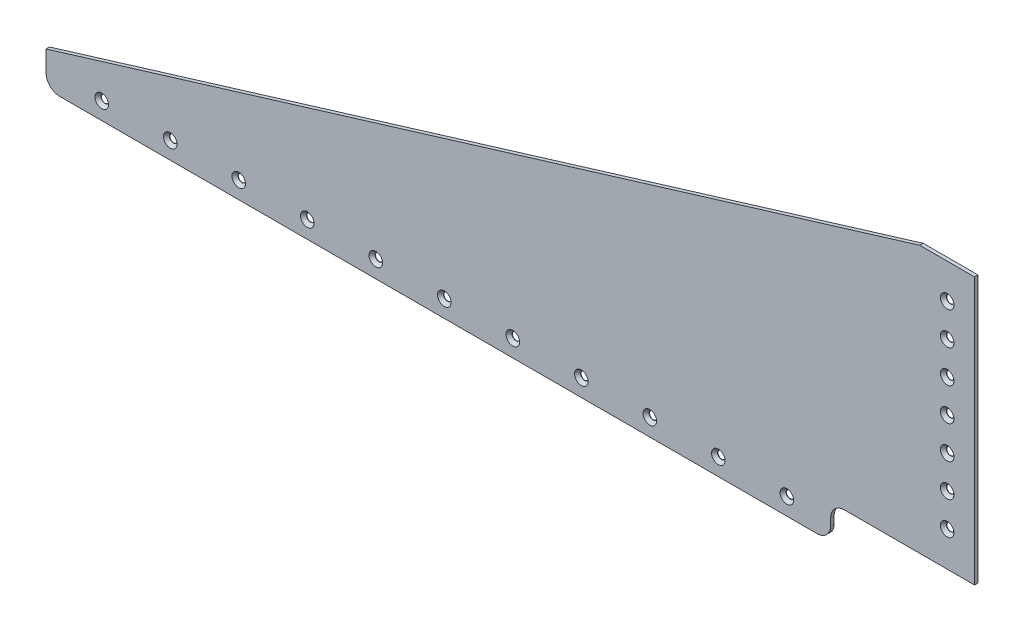
from build123d import *

# Parameters (mm, degrees)
BOSS_EXTRUDE1_DEPTH                           = 1.5875
CSK_FOR_6_FLAT_HEAD_SOCKET_CAP_SCREW1_A_COUNT = 2
CSK_FOR_6_FLAT_HEAD_SOCKET_CAP_SCREW1_A_PITCH = 31.75
CSK_FOR_6_FLAT_HEAD_SOCKET_CAP_SCRE_2_COUNT   = 2
CSK_FOR_6_FLAT_HEAD_SOCKET_CAP_SCRE_2_PITCH   = 63.5
CSK_FOR_6_FLAT_HEAD_SOCKET_CAP_SCRE_3_COUNT   = 2
CSK_FOR_6_FLAT_HEAD_SOCKET_CAP_SCRE_3_PITCH   = 95.25
CSK_FOR_6_FLAT_HEAD_SOCKET_CAP_SCRE_4_COUNT   = 2
CSK_FOR_6_FLAT_HEAD_SOCKET_CAP_SCRE_4_PITCH   = 127
CSK_FOR_6_FLAT_HEAD_SOCKET_CAP_SCRE_5_COUNT   = 2
CSK_FOR_6_FLAT_HEAD_SOCKET_CAP_SCRE_5_PITCH   = 158.75
CSK_FOR_6_FLAT_HEAD_SOCKET_CAP_SCRE_6_COUNT   = 2
CSK_FOR_6_FLAT_HEAD_SOCKET_CAP_SCRE_6_PITCH   = 190.5
CSK_FOR_6_FLAT_HEAD_SOCKET_CAP_SCRE_7_COUNT   = 2
CSK_FOR_6_FLAT_HEAD_SOCKET_CAP_SCRE_7_PITCH   = 222.25
CSK_FOR_6_FLAT_HEAD_SOCKET_CAP_SCRE_8_COUNT   = 2
CSK_FOR_6_FLAT_HEAD_SOCKET_CAP_SCRE_8_PITCH   = 254
CSK_FOR_6_FLAT_HEAD_SOCKET_CAP_SCRE_9_COUNT   = 2
CSK_FOR_6_FLAT_HEAD_SOCKET_CAP_SCRE_9_PITCH   = 285.75
CSK_FOR_6_FLAT_HEAD_SOCKET_CAP_SCRE_10_COUNT  = 2
CSK_FOR_6_FLAT_HEAD_SOCKET_CAP_SCRE_10_PITCH  = 317.5
CSK_FOR_6_FLAT_HEAD_SOCKET_CAP_SCREW2_A_COUNT = 2
CSK_FOR_6_FLAT_HEAD_SOCKET_CAP_SCREW2_A_PITCH = 15.24
CSK_FOR_6_FLAT_HEAD_SOCKET_CAP_SCRE_11_COUNT  = 2
CSK_FOR_6_FLAT_HEAD_SOCKET_CAP_SCRE_11_PITCH  = 30.48
CSK_FOR_6_FLAT_HEAD_SOCKET_CAP_SCRE_12_COUNT  = 2
CSK_FOR_6_FLAT_HEAD_SOCKET_CAP_SCRE_12_PITCH  = 45.72
CSK_FOR_6_FLAT_HEAD_SOCKET_CAP_SCRE_13_COUNT  = 2
CSK_FOR_6_FLAT_HEAD_SOCKET_CAP_SCRE_13_PITCH  = 60.96
CSK_FOR_6_FLAT_HEAD_SOCKET_CAP_SCRE_14_COUNT  = 2
CSK_FOR_6_FLAT_HEAD_SOCKET_CAP_SCRE_14_PITCH  = 76.2
CSK_FOR_6_FLAT_HEAD_SOCKET_CAP_SCRE_15_COUNT  = 2
CSK_FOR_6_FLAT_HEAD_SOCKET_CAP_SCRE_15_PITCH  = 91.44


with BuildPart() as part:
    # Sketch1 → Boss-Extrude1 (new body)
    with BuildSketch(Plane.XY):
        with BuildLine():
            Line((0, 15.875), (404.9268, 139.5476))
            Line((404.9268, 139.5476), (430.3268, 139.5476))
            Line((430.3268, 139.5476), (430.3268, 15.875))
            Line((430.3268, 15.875), (370.0018, 15.875))
            ThreePointArc((370.0018, 15.875), (365.511671939, 14.015128061), (363.6518, 9.525))
            Line((363.6518, 9.525), (363.6518, 6.35))
            ThreePointArc((363.6518, 6.35), (361.791928061, 1.859871939), (357.3018, 0))
            Line((357.3018, 0), (6.35, 0))
            ThreePointArc((6.35, 0), (1.859871939, 1.859871939), (0, 6.35))
            Line((0, 6.35), (0, 15.875))
        make_face()
    extrude(amount=BOSS_EXTRUDE1_DEPTH)

    # Sketch3 → CSK for #6 Flat Head Socket Cap Screw1 (revolve, cut)
    with BuildSketch(Plane(origin=(343.3318, 7.9375, 1.5875), x_dir=(0, -1, 0), z_dir=(1, 0, 0))):
        Polygon((0, 0), (0, 2.6228539), (1.8288, 1.524), (1.8288, 1.504796913), (3.1369, 0), align=None)
    csk_for_6_flat_head_socket_cap_screw1 = revolve(axis=Axis((343.3318, 7.9375, 7.9375), (0, 0, -1)), mode=Mode.SUBTRACT)

    # CSK for #6 Flat Head Socket Cap Screw1 a: CSK for #6 Flat Head Socket Cap Screw1 ×2
    with Locations(*[(-i * CSK_FOR_6_FLAT_HEAD_SOCKET_CAP_SCREW1_A_PITCH, 0, 0) for i in range(1, CSK_FOR_6_FLAT_HEAD_SOCKET_CAP_SCREW1_A_COUNT)]):
        add(csk_for_6_flat_head_socket_cap_screw1, mode=Mode.SUBTRACT)

    # CSK for _6 Flat Head Socket Cap Scre 2: CSK for #6 Flat Head Socket Cap Screw1 ×2
    with Locations(*[(-i * CSK_FOR_6_FLAT_HEAD_SOCKET_CAP_SCRE_2_PITCH, 0, 0) for i in range(1, CSK_FOR_6_FLAT_HEAD_SOCKET_CAP_SCRE_2_COUNT)]):
        add(csk_for_6_flat_head_socket_cap_screw1, mode=Mode.SUBTRACT)

    # CSK for _6 Flat Head Socket Cap Scre 3: CSK for #6 Flat Head Socket Cap Screw1 ×2
    with Locations(*[(-i * CSK_FOR_6_FLAT_HEAD_SOCKET_CAP_SCRE_3_PITCH, 0, 0) for i in range(1, CSK_FOR_6_FLAT_HEAD_SOCKET_CAP_SCRE_3_COUNT)]):
        add(csk_for_6_flat_head_socket_cap_screw1, mode=Mode.SUBTRACT)

    # CSK for _6 Flat Head Socket Cap Scre 4: CSK for #6 Flat Head Socket Cap Screw1 ×2
    with Locations(*[(-i * CSK_FOR_6_FLAT_HEAD_SOCKET_CAP_SCRE_4_PITCH, 0, 0) for i in range(1, CSK_FOR_6_FLAT_HEAD_SOCKET_CAP_SCRE_4_COUNT)]):
        add(csk_for_6_flat_head_socket_cap_screw1, mode=Mode.SUBTRACT)

    # CSK for _6 Flat Head Socket Cap Scre 5: CSK for #6 Flat Head Socket Cap Screw1 ×2
    with Locations(*[(-i * CSK_FOR_6_FLAT_HEAD_SOCKET_CAP_SCRE_5_PITCH, 0, 0) for i in range(1, CSK_FOR_6_FLAT_HEAD_SOCKET_CAP_SCRE_5_COUNT)]):
        add(csk_for_6_flat_head_socket_cap_screw1, mode=Mode.SUBTRACT)

    # CSK for _6 Flat Head Socket Cap Scre 6: CSK for #6 Flat Head Socket Cap Screw1 ×2
    with Locations(*[(-i * CSK_FOR_6_FLAT_HEAD_SOCKET_CAP_SCRE_6_PITCH, 0, 0) for i in range(1, CSK_FOR_6_FLAT_HEAD_SOCKET_CAP_SCRE_6_COUNT)]):
        add(csk_for_6_flat_head_socket_cap_screw1, mode=Mode.SUBTRACT)

    # CSK for _6 Flat Head Socket Cap Scre 7: CSK for #6 Flat Head Socket Cap Screw1 ×2
    with Locations(*[(-i * CSK_FOR_6_FLAT_HEAD_SOCKET_CAP_SCRE_7_PITCH, 0, 0) for i in range(1, CSK_FOR_6_FLAT_HEAD_SOCKET_CAP_SCRE_7_COUNT)]):
        add(csk_for_6_flat_head_socket_cap_screw1, mode=Mode.SUBTRACT)

    # CSK for _6 Flat Head Socket Cap Scre 8: CSK for #6 Flat Head Socket Cap Screw1 ×2
    with Locations(*[(-i * CSK_FOR_6_FLAT_HEAD_SOCKET_CAP_SCRE_8_PITCH, 0, 0) for i in range(1, CSK_FOR_6_FLAT_HEAD_SOCKET_CAP_SCRE_8_COUNT)]):
        add(csk_for_6_flat_head_socket_cap_screw1, mode=Mode.SUBTRACT)

    # CSK for _6 Flat Head Socket Cap Scre 9: CSK for #6 Flat Head Socket Cap Screw1 ×2
    with Locations(*[(-i * CSK_FOR_6_FLAT_HEAD_SOCKET_CAP_SCRE_9_PITCH, 0, 0) for i in range(1, CSK_FOR_6_FLAT_HEAD_SOCKET_CAP_SCRE_9_COUNT)]):
        add(csk_for_6_flat_head_socket_cap_screw1, mode=Mode.SUBTRACT)

    # CSK for _6 Flat Head Socket Cap Scre 10: CSK for #6 Flat Head Socket Cap Screw1 ×2
    with Locations(*[(-i * CSK_FOR_6_FLAT_HEAD_SOCKET_CAP_SCRE_10_PITCH, 0, 0) for i in range(1, CSK_FOR_6_FLAT_HEAD_SOCKET_CAP_SCRE_10_COUNT)]):
        add(csk_for_6_flat_head_socket_cap_screw1, mode=Mode.SUBTRACT)

    # Sketch5 → CSK for #6 Flat Head Socket Cap Screw2 (revolve, cut)
    with BuildSketch(Plane(origin=(417.6268, 123.4313, 1.5875), x_dir=(0, -1, 0), z_dir=(1, 0, 0))):
        Polygon((0, 0), (0, 2.6228539), (1.8288, 1.524), (1.8288, 1.504796913), (3.1369, 0), align=None)
    csk_for_6_flat_head_socket_cap_screw2 = revolve(axis=Axis((417.6268, 123.4313, 7.9375), (0, 0, -1)), mode=Mode.SUBTRACT)

    # CSK for #6 Flat Head Socket Cap Screw2 a: CSK for #6 Flat Head Socket Cap Screw2 ×2
    with Locations(*[(0, -i * CSK_FOR_6_FLAT_HEAD_SOCKET_CAP_SCREW2_A_PITCH, 0) for i in range(1, CSK_FOR_6_FLAT_HEAD_SOCKET_CAP_SCREW2_A_COUNT)]):
        add(csk_for_6_flat_head_socket_cap_screw2, mode=Mode.SUBTRACT)

    # CSK for _6 Flat Head Socket Cap Scre 11: CSK for #6 Flat Head Socket Cap Screw2 ×2
    with Locations(*[(0, -i * CSK_FOR_6_FLAT_HEAD_SOCKET_CAP_SCRE_11_PITCH, 0) for i in range(1, CSK_FOR_6_FLAT_HEAD_SOCKET_CAP_SCRE_11_COUNT)]):
        add(csk_for_6_flat_head_socket_cap_screw2, mode=Mode.SUBTRACT)

    # CSK for _6 Flat Head Socket Cap Scre 12: CSK for #6 Flat Head Socket Cap Screw2 ×2
    with Locations(*[(0, -i * CSK_FOR_6_FLAT_HEAD_SOCKET_CAP_SCRE_12_PITCH, 0) for i in range(1, CSK_FOR_6_FLAT_HEAD_SOCKET_CAP_SCRE_12_COUNT)]):
        add(csk_for_6_flat_head_socket_cap_screw2, mode=Mode.SUBTRACT)

    # CSK for _6 Flat Head Socket Cap Scre 13: CSK for #6 Flat Head Socket Cap Screw2 ×2
    with Locations(*[(0, -i * CSK_FOR_6_FLAT_HEAD_SOCKET_CAP_SCRE_13_PITCH, 0) for i in range(1, CSK_FOR_6_FLAT_HEAD_SOCKET_CAP_SCRE_13_COUNT)]):
        add(csk_for_6_flat_head_socket_cap_screw2, mode=Mode.SUBTRACT)

    # CSK for _6 Flat Head Socket Cap Scre 14: CSK for #6 Flat Head Socket Cap Screw2 ×2
    with Locations(*[(0, -i * CSK_FOR_6_FLAT_HEAD_SOCKET_CAP_SCRE_14_PITCH, 0) for i in range(1, CSK_FOR_6_FLAT_HEAD_SOCKET_CAP_SCRE_14_COUNT)]):
        add(csk_for_6_flat_head_socket_cap_screw2, mode=Mode.SUBTRACT)

    # CSK for _6 Flat Head Socket Cap Scre 15: CSK for #6 Flat Head Socket Cap Screw2 ×2
    with Locations(*[(0, -i * CSK_FOR_6_FLAT_HEAD_SOCKET_CAP_SCRE_15_PITCH, 0) for i in range(1, CSK_FOR_6_FLAT_HEAD_SOCKET_CAP_SCRE_15_COUNT)]):
        add(csk_for_6_flat_head_socket_cap_screw2, mode=Mode.SUBTRACT)


solid = part.part
